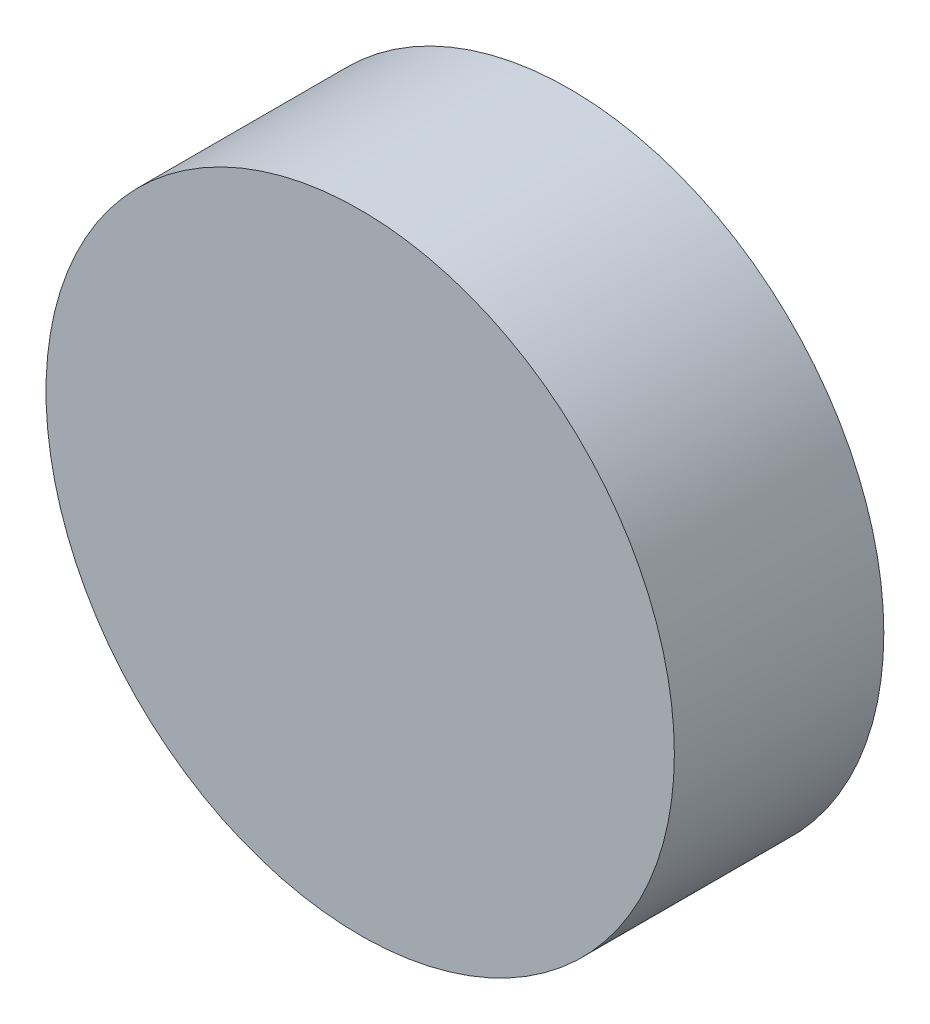
from build123d import *

# Parameters (mm, degrees)
SKETCH1_R           = 60
BOSS_EXTRUDE1_DEPTH = 40


with BuildPart() as part:
    # Sketch1 → Boss-Extrude1 (new body)
    with BuildSketch(Plane.XY):
        Circle(SKETCH1_R)
    extrude(amount=BOSS_EXTRUDE1_DEPTH)


solid = part.part
